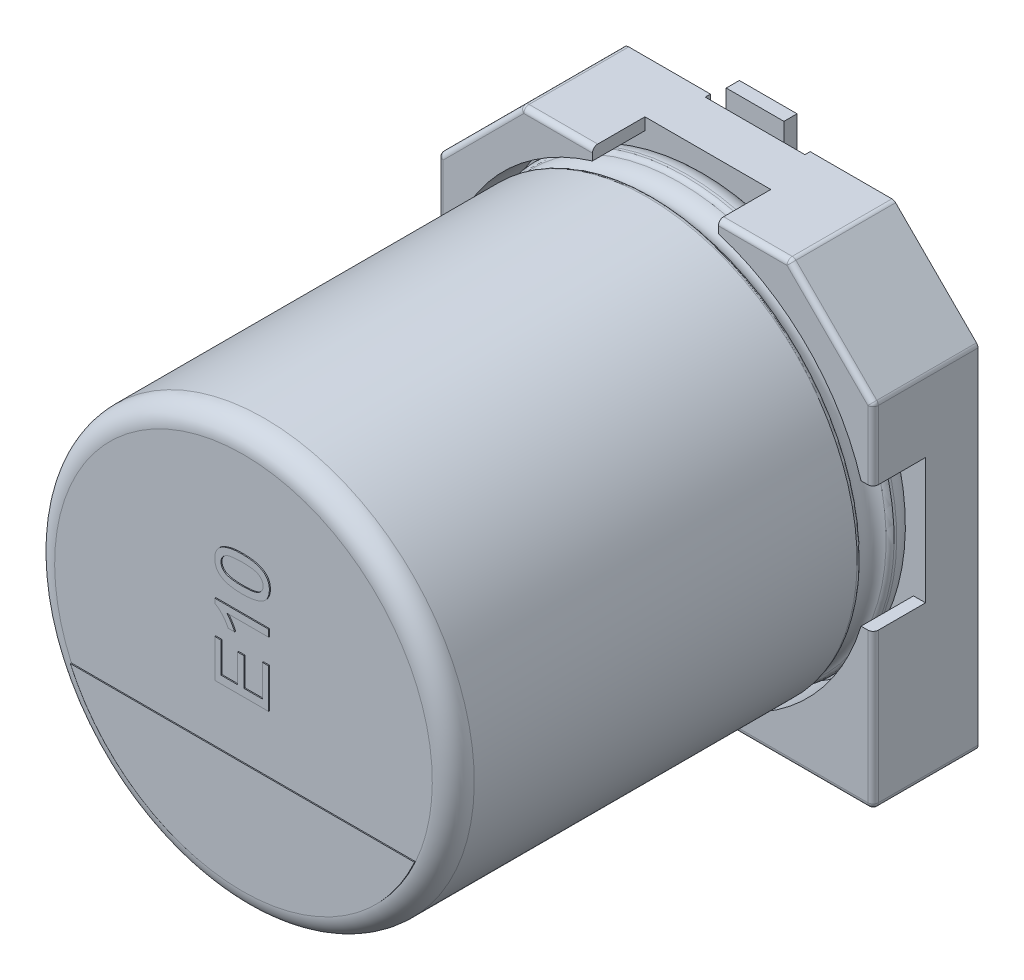
from build123d import *

# Parameters (mm, degrees)
BOSS_EXTRUDE1_DEPTH  = 1
BOSS_EXTRUDE2_DEPTH  = 1
SKETCH7_R            = 0.35
SPACER_PAD_DEPTH     = 0.15
SKETCH9_W            = 1.9
SKETCH9_H            = 2.65
CUT_EXTRUDE1_DEPTH   = 0.1
FILLET1_R            = 0.1
FILLET2_R            = 0.1
CATHODE_MARKER_DEPTH = 0.02
TEXT_2_DEPTH         = 0.02
SKETCH19_W           = 1.1
SKETCH19_H           = 2.9
BOSS_EXTRUDE6_DEPTH  = 0.25


with BuildPart() as part:
    # Sketch2 → Boss-Extrude1 (new body)
    with BuildSketch(Plane.XY):
        Polygon((-4.15, 2.55), (-2.55, 4.15), (2.55, 4.15), (4.15, 2.55), (4.15, -4.15), (-4.15, -4.15), align=None)
    extrude(amount=BOSS_EXTRUDE1_DEPTH)

    # Sketch4 → Boss-Extrude2 (add)
    with BuildSketch(Plane.XY.offset(1)):
        with BuildLine():
            Line((-4.15, 2.55), (-2.55, 4.15))
            Line((-2.55, 4.15), (-1.2, 4.15))
            Line((-1.2, 4.15), (-1.2, 3.920459157))
            ThreePointArc((-1.2, 3.920459157), (-2.899137803, 2.899137803), (-3.920459157, 1.2))
            Line((-3.920459157, 1.2), (-4.15, 1.2))
            Line((-4.15, 1.2), (-4.15, 2.55))
        make_face()
        with BuildLine():
            Line((2.55, 4.15), (4.15, 2.55))
            Line((4.15, 2.55), (4.15, 1.2))
            Line((4.15, 1.2), (3.920459157, 1.2))
            ThreePointArc((3.920459157, 1.2), (2.899137803, 2.899137803), (1.2, 3.920459157))
            Line((1.2, 3.920459157), (1.2, 4.15))
            Line((1.2, 4.15), (2.55, 4.15))
        make_face()
        with BuildLine():
            Line((4.15, -1.2), (4.15, -4.15))
            Line((4.15, -4.15), (1.2, -4.15))
            Line((1.2, -4.15), (1.2, -3.920459157))
            ThreePointArc((1.2, -3.920459157), (2.899137803, -2.899137803), (3.920459157, -1.2))
            Line((3.920459157, -1.2), (4.15, -1.2))
        make_face()
        with BuildLine():
            Line((-4.15, -1.2), (-4.15, -4.15))
            Line((-4.15, -4.15), (-1.2, -4.15))
            Line((-1.2, -4.15), (-1.2, -3.920459157))
            ThreePointArc((-1.2, -3.920459157), (-2.899137803, -2.899137803), (-3.920459157, -1.2))
            Line((-3.920459157, -1.2), (-4.15, -1.2))
        make_face()
    extrude(amount=BOSS_EXTRUDE2_DEPTH)

    # Sketch7 → Spacer Pad (add)
    with BuildSketch(Plane(origin=(0, 0, 0), x_dir=(1, 0, 0), z_dir=(0, 0, -1))):
        with Locations((-2.906501466, 2.844859418)):
            Circle(SKETCH7_R)
        with Locations((2.906501466, 2.844859418)):
            Circle(SKETCH7_R)
        with Locations((-2.906501466, -2.844859418)):
            Circle(SKETCH7_R)
        with Locations((2.906501466, -2.844859418)):
            Circle(SKETCH7_R)
    extrude(amount=SPACER_PAD_DEPTH)

    # Sketch9 → Cut-Extrude1 (cut)
    with BuildSketch(Plane(origin=(0, 0, 0), x_dir=(1, 0, 0), z_dir=(0, 0, -1))):
        with Locations((0, 2.825)):
            Rectangle(SKETCH9_W, SKETCH9_H)
        with Locations((0, -2.825)):
            Rectangle(SKETCH9_W, SKETCH9_H)
    extrude(amount=-CUT_EXTRUDE1_DEPTH, mode=Mode.SUBTRACT)

    # Fillet1
    fillet1_edges = [part.edges().sort_by_distance(p)[0] for p in [
        (4.15, -4.15, 1),
        (-4.15, -4.15, 1),
        (-4.15, 2.55, 1),
        (-2.55, 4.15, 1),
        (2.55, 4.15, 1),
        (4.15, 2.55, 1),
    ]]
    fillet(fillet1_edges, radius=FILLET1_R)

    # Sketch10 → Revolve1 (revolve)
    with BuildSketch(Plane(origin=(0, 0, 0), x_dir=(0, 0, -1), z_dir=(1, 0, 0))):
        with BuildLine():
            Line((-9.853626625, 0), (-1, 0))
            Line((-1, 0), (-1, 3.6))
            ThreePointArc((-1, 3.6), (-1.117157288, 3.882842712), (-1.4, 4))
            Line((-1.4, 4), (-1.449422929, 4))
            ThreePointArc((-1.449422929, 4), (-1.504479696, 3.983479053), (-1.541344666, 3.939375046))
            ThreePointArc((-1.541344666, 3.939375046), (-1.801990181, 3.767472047), (-2.062635697, 3.939375046))
            ThreePointArc((-2.062635697, 3.939375046), (-2.099500666, 3.983479053), (-2.154557434, 4))
            Line((-2.154557434, 4), (-9.453626625, 4))
            ThreePointArc((-9.453626625, 4), (-9.736469337, 3.882842712), (-9.853626625, 3.6))
            Line((-9.853626625, 3.6), (-9.853626625, 0))
        make_face()
    revolve(axis=Axis((0, 0, -18.9630778), (0, 0, 1)))

    # Fillet2
    fillet2_edges = [part.edges().sort_by_distance(p)[0] for p in [
        (2.625, -4.15, 2),
        (4.120710678, -4.120710678, 2),
        (4.15, 1.854289322, 2),
        (4.142387953, 2.546846987, 2),
        (1.854289322, 4.15, 2),
        (2.546846987, 4.142387953, 2),
        (-1.854289322, 4.15, 2),
        (-2.546846987, 4.142387953, 2),
        (-3.35, 3.35, 2),
        (-4.142387953, 2.546846987, 2),
        (-4.15, -2.625, 2),
        (-4.120710678, -4.120710678, 2),
        (4.15, -2.625, 2),
        (3.35, 3.35, 2),
        (-4.15, 1.854289322, 2),
        (-2.625, -4.15, 2),
    ]]
    fillet(fillet2_edges, radius=FILLET2_R)

    # Sketch13 → Cathode marker (add)
    with BuildSketch(Plane.XY.offset(9.853626625)):
        with BuildLine():
            Line((-3.280894476, -1.481800067), (3.280894476, -1.481800067))
            ThreePointArc((3.280894476, -1.481800067), (0, -3.6), (-3.280894476, -1.481800067))
        make_face()
    extrude(amount=CATHODE_MARKER_DEPTH)

    # Sketch15 → Text 2 (add)
    with BuildSketch(Plane.XY.offset(9.853626625)):
        Polygon((0.5, -0.381462215), (-0.527327474, -0.381462215), (-0.527327474, 0.342935363), (-0.408789689, 0.342935363), (-0.408789689, -0.236582699), (-0.092688927, -0.236582699), (-0.092688927, 0.303422768), (0.025848858, 0.303422768), (0.025848858, -0.236582699), (0.381462215, -0.236582699), (0.381462215, 0.369277093), (0.5, 0.369277093), align=None)
        with BuildLine():
            Line((0.5, 0.975136886), (0.5, 0.843428235))
            Line((0.5, 0.843428235), (-0.300541641, 0.843428235))
            add(Edge.make_bspline(
                [(-0.300541641, 0.843428235), (-0.293231008, 0.835842223), (-0.278036657, 0.820075527), (-0.256498368, 0.793500467), (-0.234933587, 0.763635908), (-0.213972558, 0.731200604), (-0.193975357, 0.698239233), (-0.17626551, 0.666212427), (-0.16122985, 0.635905104), (-0.153017422, 0.615935207), (-0.149076693, 0.606352664)],
                knots=[0, 0, 0, 0, 0.893410138, 1.856855062, 2.898678959, 4.017251132, 5.132047586, 6.168690112, 7.121247105, 8, 8, 8, 8], degree=3))
            Line((-0.149076693, 0.606352664), (-0.270495605, 0.606352664))
            add(Edge.make_bspline(
                [(-0.270495605, 0.606352664), (-0.278975965, 0.622807623), (-0.295690253, 0.655239372), (-0.324502419, 0.701148466), (-0.356038954, 0.743792464), (-0.389687464, 0.782917924), (-0.424153619, 0.81780935), (-0.458713989, 0.84744292), (-0.492500166, 0.87204352), (-0.516061848, 0.884428006), (-0.527327474, 0.890349442)],
                knots=[0, 0, 0, 0, 1.141359047, 2.249551097, 3.338622382, 4.409719606, 5.42990334, 6.36011437, 7.215916014, 8, 8, 8, 8], degree=3))
            Line((-0.527327474, 0.890349442), (-0.527327474, 0.975136886))
            Line((-0.527327474, 0.975136886), (0.5, 0.975136886))
        make_face()
        with BuildLine():
            add(Edge.make_bspline(
                [(-0.006666715, 1.304408512), (-0.021348161, 1.304541244), (-0.05010293, 1.304801211), (-0.092176441, 1.306412763), (-0.132131476, 1.309229042), (-0.169935305, 1.313424251), (-0.205733207, 1.318429799), (-0.239429592, 1.324842372), (-0.271062963, 1.332159315), (-0.300511033, 1.340835277), (-0.328087047, 1.350518234), (-0.353841772, 1.361354927), (-0.37776862, 1.373587678), (-0.400036721, 1.386687211), (-0.420488167, 1.400907311), (-0.439160067, 1.416230001), (-0.456112672, 1.432681732), (-0.471148561, 1.450433576), (-0.484427043, 1.469315313), (-0.495950274, 1.489276059), (-0.505765593, 1.510457429), (-0.513455163, 1.532919783), (-0.519644259, 1.556444314), (-0.524219468, 1.581124159), (-0.526911348, 1.607003303), (-0.527187198, 1.624687403), (-0.527327474, 1.633680138)],
                knots=[0, 0, 0, 0, 1.514579231, 2.966422906, 4.342888004, 5.645649548, 6.889653673, 8.070797339, 9.183112822, 10.237837631, 11.23608981, 12.196917133, 13.117904763, 14.006315217, 14.860292005, 15.684850496, 16.495566347, 17.293863258, 18.081168691, 18.873799386, 19.668575398, 20.485475899, 21.319695627, 22.176102692, 23.072510053, 24, 24, 24, 24], degree=3))
            add(Edge.make_bspline(
                [(-0.527327474, 1.633680138), (-0.526946, 1.646875661), (-0.52619658, 1.672798793), (-0.519894074, 1.710594714), (-0.509601404, 1.746340172), (-0.495164597, 1.779746523), (-0.477005039, 1.810526209), (-0.454609486, 1.837789159), (-0.428796734, 1.861696165), (-0.398935516, 1.881673025), (-0.365916888, 1.899150411), (-0.32956484, 1.9146724), (-0.289928116, 1.928705175), (-0.254447235, 1.938662815), (-0.223818989, 1.945765666), (-0.198557662, 1.950467178), (-0.171300552, 1.954370379), (-0.142113597, 1.957360757), (-0.111029533, 1.959814292), (-0.078029007, 1.961709045), (-0.043029539, 1.962670826), (-0.019014885, 1.962856363), (-0.006666715, 1.962951764)],
                knots=[0, 0, 0, 0, 1.134369906, 2.228515181, 3.285355733, 4.326599491, 5.350616376, 6.348601676, 7.350764122, 8.365406289, 9.429174435, 10.560286681, 11.762070813, 13.043401781, 13.727542782, 14.465843617, 15.252693982, 16.095180924, 16.988916914, 17.934437918, 18.937902156, 20, 20, 20, 20], degree=3))
            add(Edge.make_bspline(
                [(-0.006666715, 1.962951764), (0.007945774, 1.962816571), (0.036494148, 1.962552445), (0.078230238, 1.96098374), (0.117884052, 1.957999092), (0.155547122, 1.954328962), (0.191116489, 1.948767516), (0.224685881, 1.942815715), (0.256141409, 1.935356758), (0.285591451, 1.926709212), (0.313215971, 1.917051436), (0.339056183, 1.906411823), (0.363042027, 1.894415025), (0.385265653, 1.881290289), (0.405728202, 1.86700423), (0.424578214, 1.851816242), (0.441550249, 1.83529661), (0.456560003, 1.817480993), (0.470080131, 1.798725644), (0.481656405, 1.778658773), (0.49124711, 1.757367865), (0.499446696, 1.734995266), (0.50545487, 1.711313948), (0.510054034, 1.686510667), (0.512762354, 1.660494032), (0.513032816, 1.64274142), (0.513170865, 1.633680138)],
                knots=[0, 0, 0, 0, 1.509004079, 2.9481365, 4.311841541, 5.615149582, 6.854413858, 8.028470806, 9.134999426, 10.19077436, 11.196702255, 12.155743144, 13.07445799, 13.963752978, 14.818580019, 15.649443378, 16.460966408, 17.260058134, 18.052243746, 18.845663614, 19.647670084, 20.461076897, 21.302979722, 22.167206202, 23.06450606, 24, 24, 24, 24], degree=3))
            add(Edge.make_bspline(
                [(0.513170865, 1.633680138), (0.512831976, 1.621799747), (0.512171236, 1.598636255), (0.507681916, 1.564807682), (0.499780502, 1.533057762), (0.489183591, 1.503118702), (0.475009612, 1.475327027), (0.457764199, 1.44955004), (0.437848585, 1.425269773), (0.422135623, 1.411292576), (0.414183582, 1.404218974)],
                knots=[0, 0, 0, 0, 1.10322584, 2.150986741, 3.161425019, 4.136713905, 5.093944212, 6.049774532, 7.013026876, 8, 8, 8, 8], degree=3))
            add(Edge.make_bspline(
                [(0.414183582, 1.404218974), (0.402438803, 1.396077095), (0.378220566, 1.379288193), (0.336926225, 1.359638239), (0.291466953, 1.342110132), (0.240950845, 1.328353782), (0.185779952, 1.317579131), (0.125846017, 1.309797142), (0.061174934, 1.305393303), (0.016457663, 1.304744186), (-0.006666715, 1.304408512)],
                knots=[0, 0, 0, 0, 0.779365345, 1.607084704, 2.489375761, 3.438383567, 4.461919411, 5.557722155, 6.737039282, 8, 8, 8, 8], degree=3))
        make_face()
        with BuildLine():
            add(Edge.make_bspline(
                [(-0.007078304, 1.436117162), (0.012680939, 1.436247939), (0.050504503, 1.436498273), (0.104541989, 1.439113662), (0.153291178, 1.443615947), (0.196684572, 1.449568261), (0.234780871, 1.457427725), (0.267482993, 1.467296213), (0.295183438, 1.478420345), (0.31753888, 1.492186249), (0.335761826, 1.507258392), (0.351434149, 1.52281935), (0.364755265, 1.539235219), (0.375862359, 1.556398885), (0.384271921, 1.574576658), (0.39036719, 1.593569764), (0.393874924, 1.613382338), (0.394378919, 1.6268756), (0.39463308, 1.633680138)],
                knots=[0, 0, 0, 0, 1.89448813, 3.626469325, 5.185477471, 6.587276848, 7.82441448, 8.910550357, 9.859733512, 10.6775885, 11.416198291, 12.123144072, 12.791880183, 13.439617036, 14.078171869, 14.70637855, 15.347637704, 16, 16, 16, 16], degree=3))
            add(Edge.make_bspline(
                [(0.39463308, 1.633680138), (0.394373432, 1.640483027), (0.393858557, 1.65397302), (0.390427197, 1.673830568), (0.384021797, 1.692752786), (0.375628132, 1.710892073), (0.364803962, 1.728260954), (0.351188379, 1.744451889), (0.335563636, 1.760187262), (0.31713255, 1.775098704), (0.294785049, 1.788955473), (0.267067011, 1.800058591), (0.234370941, 1.809935976), (0.196338005, 1.817769737), (0.153019756, 1.823764385), (0.104403712, 1.828233835), (0.050436387, 1.830868446), (0.012681078, 1.831114396), (-0.007078304, 1.831243114)],
                knots=[0, 0, 0, 0, 0.652578524, 1.294050225, 1.924494109, 2.563260593, 3.207694917, 3.880813851, 4.587993952, 5.331957758, 6.150083828, 7.099581593, 8.186077474, 9.42362516, 10.819375359, 12.378900244, 14.104883934, 16, 16, 16, 16], degree=3))
            add(Edge.make_bspline(
                [(-0.007078304, 1.831243114), (-0.02642651, 1.831118388), (-0.063496939, 1.830879418), (-0.116493392, 1.828178621), (-0.164424345, 1.823946228), (-0.207333987, 1.818156987), (-0.245175733, 1.810463087), (-0.278030144, 1.801131436), (-0.305827152, 1.790011378), (-0.328845978, 1.77678967), (-0.34772766, 1.762071262), (-0.364071399, 1.74669649), (-0.377971216, 1.730280983), (-0.389121855, 1.712533908), (-0.398117775, 1.694027285), (-0.404308997, 1.67433588), (-0.40811269, 1.653653244), (-0.408561444, 1.639459019), (-0.408789689, 1.632239575)],
                knots=[0, 0, 0, 0, 1.850066095, 3.544656626, 5.0727657, 6.45041401, 7.682899467, 8.762389858, 9.712573485, 10.538438529, 11.291566246, 11.996865408, 12.681389046, 13.341983376, 13.996294293, 14.643563182, 15.31009126, 16, 16, 16, 16], degree=3))
            add(Edge.make_bspline(
                [(-0.408789689, 1.632239575), (-0.408612967, 1.625434588), (-0.408264494, 1.612016027), (-0.404876647, 1.592384601), (-0.399346117, 1.573695426), (-0.39136817, 1.556072877), (-0.381470743, 1.539342521), (-0.369432495, 1.523484056), (-0.354882974, 1.508877705), (-0.343982304, 1.500087181), (-0.338407878, 1.49559185)],
                knots=[0, 0, 0, 0, 1.021462953, 2.014194051, 2.982449609, 3.941891643, 4.91211921, 5.897280499, 6.924703483, 8, 8, 8, 8], degree=3))
            add(Edge.make_bspline(
                [(-0.338407878, 1.49559185), (-0.330223621, 1.490696426), (-0.312940192, 1.480358321), (-0.282899948, 1.468794891), (-0.248509791, 1.458540432), (-0.209345493, 1.450211788), (-0.165460838, 1.444048965), (-0.116925816, 1.439275892), (-0.063560809, 1.436772478), (-0.026425263, 1.436341628), (-0.007078304, 1.436117162)],
                knots=[0, 0, 0, 0, 0.671109831, 1.417242661, 2.260125669, 3.199948126, 4.23589883, 5.382398214, 6.636276086, 8, 8, 8, 8], degree=3))
        make_face(mode=Mode.SUBTRACT)
    extrude(amount=TEXT_2_DEPTH)

    # Sketch19 → Boss-Extrude6 (add)
    with BuildSketch(Plane(origin=(0, 0, 0.1), x_dir=(1, 0, 0), z_dir=(0, 0, -1))):
        with Locations((0, 3.05)):
            Rectangle(SKETCH19_W, SKETCH19_H)
        with Locations((0, -3.05)):
            Rectangle(SKETCH19_W, SKETCH19_H)
    extrude(amount=BOSS_EXTRUDE6_DEPTH)


solid = part.part
